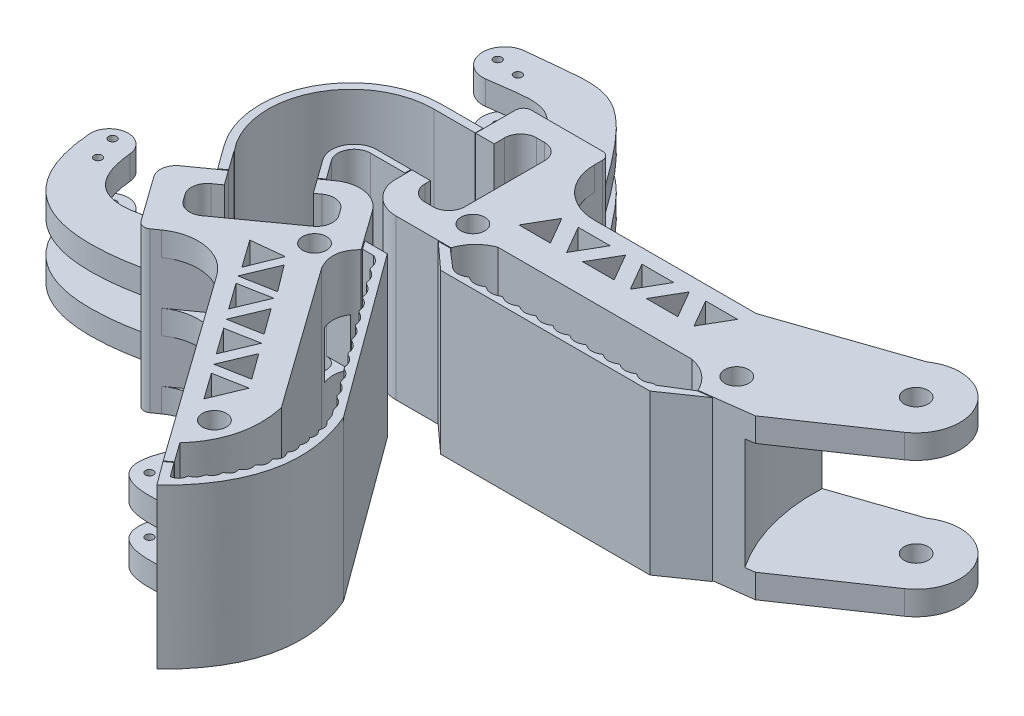
from build123d import *

# Parameters (mm, degrees)
EXTRUDE_1_DEPTH      = 20
EXTRUDE_3_DEPTH      = 20
CUT_EXTRUDE_5_DEPTH  = 5.5
CUT_EXTRUDE_6_DEPTH  = 5.5
CUT_EXTRUDE_8_DEPTH  = 35.5
EXTRUDE_5_DEPTH      = 20
SKETCH_13_R          = 22.138459571
CUT_EXTRUDE_10_DEPTH = 7
SKETCH_14_R          = 1.5
CUT_EXTRUDE_11_DEPTH = 24
SKETCH_15_R          = 1.5
CUT_EXTRUDE_12_DEPTH = 24
CUT_EXTRUDE_14_DEPTH = 3
SKETCH_17_W          = 3.321417058
SKETCH_17_H          = 8
CUT_EXTRUDE_15_DEPTH = 26
EXTRUDE_6_DEPTH      = 20
EXTRUDE_6_2_DEPTH    = 20
EXTRUDE_7_DEPTH      = 20
CUT_EXTRUDE_17_DEPTH = 30
CUT_EXTRUDE_20_DEPTH = 5.5
CUT_EXTRUDE_21_DEPTH = 5.5
CUT_EXTRUDE_23_DEPTH = 35.5
CUT_EXTRUDE_24_DEPTH = 35.5
CUT_EXTRUDE_25_DEPTH = 35.5
SKETCH_33_R          = 1.5
CUT_EXTRUDE_26_DEPTH = 20
EXTRUDE_9_DEPTH      = 20
CUT_EXTRUDE_27_DEPTH = 3
EXTRUDE_10_DEPTH     = 5
CUT_EXTRUDE_28_DEPTH = 2
SKETCH_37_R          = 0.5
CUT_EXTRUDE_29_DEPTH = 7
EXTRUDE_13_DEPTH     = 5
EXTRUDE_14_DEPTH     = 5
SKETCH_45_W          = 26.316708413
SKETCH_45_H          = 13.598677245
CUT_EXTRUDE_31_DEPTH = 2
SKETCH_46_R          = 0.5
CUT_EXTRUDE_32_DEPTH = 12


with BuildPart() as part:
    # 草图1 → 凸台-拉伸1 (new body)
    with BuildSketch(Plane(origin=(0, 0, 0), x_dir=(1, 0, 0), z_dir=(0, 1, 0))):
        with BuildLine():
            Line((-17.757352941, 11.257352941), (-17.757352941, 12.257352941))
            ThreePointArc((-17.757352941, 12.257352941), (-18.05024616, 12.964459722), (-18.757352941, 13.257352941))
            Line((-18.757352941, 13.257352941), (-27.669117647, 13.257352941))
            ThreePointArc((-27.669117647, 13.257352941), (-28.376224428, 12.964459722), (-28.669117647, 12.257352941))
            Line((-28.669117647, 12.257352941), (-28.669117647, -2.742647059))
            ThreePointArc((-28.669117647, -2.742647059), (-27.497544772, -5.571074184), (-24.669117647, -6.742647059))
            Line((-24.669117647, -6.742647059), (-17.757352941, -6.742647059))
            add(Edge.make_bspline(
                [(-17.757352941, -6.742647059), (-16.974723436, -4.564731842), (-14.875, -3.742647059)],
                knots=[0, 0, 0, 1, 1, 1], degree=2))
            Line((-14.875, -3.742647059), (9.513778538, -3.742647059))
            add(Edge.make_bspline(
                [(9.513778538, -3.742647059), (12.09253878, -4.324174608), (13.242647059, -6.742647059)],
                knots=[0, 0, 0, 1, 1, 1], degree=2))
            Line((13.242647059, -6.742647059), (13.242647059, -3.742647059))
            Line((13.242647059, -3.742647059), (13.242647059, 5.257352941))
            Line((13.242647059, 5.257352941), (-11.757352941, 5.257352941))
            ThreePointArc((-11.757352941, 5.257352941), (-15.999993628, 7.014712254), (-17.757352941, 11.257352941))
        make_face()
    extrude(amount=EXTRUDE_1_DEPTH)

    # 草图2 → 凸台-拉伸3 (add)
    with BuildSketch(Plane(origin=(0, 20, 0), x_dir=(1, 0, 0), z_dir=(0, 1, 0))):
        with BuildLine():
            Line((13.242647059, 5.257352941), (8.547982685, 5.257352941))
            Line((8.547982685, 5.257352941), (8.547982685, 2.006423608))
            add(Edge.make_bspline(
                [(8.547982685, 2.006423608), (12.006655634, -1.762879717), (13.242647059, -6.742647059)],
                knots=[0, 0, 0, 1, 1, 1], degree=2))
            Line((13.242647059, -6.742647059), (13.242647059, 5.257352941))
        make_face()
        with BuildLine():
            ThreePointArc((30.777158792, 1.656960808), (32.220492243, 9.321684017), (24.547982685, 10.723037078))
            Line((24.547982685, 10.723037078), (8.547982685, 5.257352941))
            Line((8.547982685, 5.257352941), (13.242647059, 5.257352941))
            Line((13.242647059, 5.257352941), (13.242647059, -6.742647059))
            Line((13.242647059, -6.742647059), (19.621377553, -5.918458307))
            Line((19.621377553, -5.918458307), (30.777158792, 1.656960808))
        make_face()
    extrude(amount=-EXTRUDE_3_DEPTH)

    # 草图3 → 切除-拉伸5 (cut)
    with BuildSketch(Plane(origin=(0, 17, 0), x_dir=(1, 0, 0), z_dir=(0, 1, 0))):
        Polygon((8.55906196, -0.742647059), (16.547982685, 12.911519067), (8.547982685, 12.911519067), (-17.757352941, 12.911519067), (-17.757352941, -0.742647059), align=None)
    extrude(amount=-CUT_EXTRUDE_5_DEPTH, mode=Mode.SUBTRACT)

    # 草图8 → 切除-拉伸6 (cut)
    with BuildSketch(Plane(origin=(0, 3, 0), x_dir=(-1, 0, 0), z_dir=(0, -1, 0))):
        Polygon((17.757352941, 13.042470794), (-8.547982685, 13.042470794), (-16.547982685, 13.042470794), (-8.547982685, -0.742647059), (17.757352941, -0.742647059), align=None)
    extrude(amount=-CUT_EXTRUDE_6_DEPTH, mode=Mode.SUBTRACT)

    # 草图9 → 切除-拉伸8 (cut)
    with BuildSketch(Plane(origin=(0, 20, 0), x_dir=(1, 0, 0), z_dir=(0, 1, 0))):
        Polygon((-11.984193544, 3.457352941), (-7.984193544, 3.457352941), (-9.984193544, -0.006748674), align=None)
        Polygon((-1.984193544, -0.006748674), (-3.984193544, 3.457352941), (0.015806456, 3.457352941), align=None)
        Polygon((6.015806456, -0.006748674), (4.015806456, 3.457352941), (8.015806456, 3.457352941), align=None)
        Polygon((-5.991757146, 3.412680143), (-7.965965294, -0.006748674), (-4.017548998, -0.006748674), align=None)
        Polygon((2.008242854, 3.412680143), (3.982451002, -0.006748674), (0.034034706, -0.006748674), align=None)
        Polygon((-13.991757146, 3.412680143), (-12.017548998, -0.006748674), (-15.965965294, -0.006748674), align=None)
    extrude(amount=-CUT_EXTRUDE_8_DEPTH, mode=Mode.SUBTRACT)

    # 草图13 → 切除-拉伸10 (cut, symmetric)
    with BuildSketch(Plane(origin=(0, 10, 0), x_dir=(1, 0, 0), z_dir=(0, 1, 0))):
        with Locations((36.841923503, 6.266009929)):
            Circle(SKETCH_13_R)
    extrude(amount=CUT_EXTRUDE_10_DEPTH, both=True, mode=Mode.SUBTRACT)

    # 草图14 → 切除-拉伸11 (cut)
    with BuildSketch(Plane(origin=(0, 20, 0), x_dir=(1, 0, 0), z_dir=(0, 1, 0))):
        with Locations((27.687386184, 6.207049294)):
            Circle(SKETCH_14_R)
    extrude(amount=-CUT_EXTRUDE_11_DEPTH, mode=Mode.SUBTRACT)

    # 草图15 → 切除-拉伸12 (cut)
    with BuildSketch(Plane(origin=(0, 20, 0), x_dir=(1, 0, 0), z_dir=(0, 1, 0))):
        with Locations((14.173405038, -2.798015611)):
            Circle(SKETCH_15_R)
        with Locations((-18.955674647, -2.798015611)):
            Circle(SKETCH_15_R)
        with BuildLine():
            Line((-24.337793982, 10.577806362), (-23.337793982, 10.577806362))
            ThreePointArc((-23.337793982, 10.577806362), (-21.92358042, 9.992019924), (-21.337793982, 8.577806362))
            Line((-21.337793982, 8.577806362), (-21.337793982, -1.422193638))
            ThreePointArc((-21.337793982, -1.422193638), (-21.92358042, -2.8364072), (-23.337793982, -3.422193638))
            Line((-23.337793982, -3.422193638), (-24.337793982, -3.422193638))
            ThreePointArc((-24.337793982, -3.422193638), (-25.752007544, -2.8364072), (-26.337793982, -1.422193638))
            Line((-26.337793982, -1.422193638), (-26.337793982, 8.577806362))
            ThreePointArc((-26.337793982, 8.577806362), (-25.752007544, 9.992019924), (-24.337793982, 10.577806362))
        make_face()
    extrude(amount=-CUT_EXTRUDE_12_DEPTH, mode=Mode.SUBTRACT)

    # 草图16 → 切除-拉伸14 (cut, symmetric)
    with BuildSketch(Plane(origin=(0, 10, 0), x_dir=(1, 0, 0), z_dir=(0, 1, 0))):
        Polygon((13.082513901, -1.76847371), (10.798371522, -4.188725545), (12.980771161, -6.247155195), (15.264296175, -3.827557513), align=None)
        Polygon((-19.51774749, -4.188725545), (-17.420439331, -5.97897681), (-15.447703428, -4.005018797), (-17.935814388, -1.698067862), align=None)
    extrude(amount=CUT_EXTRUDE_14_DEPTH, both=True, mode=Mode.SUBTRACT)

    # 草图17 → 切除-拉伸15 (cut)
    with BuildSketch(Plane(origin=(0, 20, 0), x_dir=(1, 0, 0), z_dir=(0, 1, 0))):
        with Locations((-27.998502511, 3.257352941)):
            Rectangle(SKETCH_17_W, SKETCH_17_H)
    extrude(amount=-CUT_EXTRUDE_15_DEPTH, mode=Mode.SUBTRACT)

    # 草图42 → 凸台-拉伸13 (add, symmetric)
    with BuildSketch(Plane(origin=(0, 10, 0), x_dir=(1, 0, 0), z_dir=(0, 1, 0))):
        with BuildLine():
            Line((-18.757352941, 13.257352941), (-27.669117647, 13.257352941))
            add(Edge.make_bspline(
                [(-27.669117647, 13.257352941), (-30.783867563, 20.913364448), (-33.058316608, 19.487699172), (-38.943109416, 18.775725984)],
                knots=[0, 0, 0, 0, 0.972018538, 0.972018538, 0.972018538, 0.972018538], degree=3))
            ThreePointArc((-38.943109416, 18.775725984), (-42.024959974, 21.238488901), (-39.505880976, 24.274480509))
            add(Edge.make_bspline(
                [(-18.757352941, 13.257352941), (-28.734678955, 27.257974916), (-29.354714717, 25.124898659), (-39.505880976, 24.274480509)],
                knots=[0, 0, 0, 0, 0.985963459, 0.985963459, 0.985963459, 0.985963459], degree=3))
        make_face()
    extrude(amount=EXTRUDE_13_DEPTH, both=True)


with BuildPart() as body_2:
    # 草图11 → 凸台-拉伸5 (new body)
    with BuildSketch(Plane(origin=(0, 20, 0), x_dir=(1, 0, 0), z_dir=(0, 1, 0))):
        with BuildLine():
            Line((-17.757352941, -6.842647059), (-19.257352941, -6.842647059))
            Line((-19.257352941, -6.842647059), (-15.958332753, -9.842647059))
            Line((-15.958332753, -9.842647059), (10.311604906, -9.842647059))
            Line((10.311604906, -9.842647059), (14.961412516, -6.621398556))
            Line((14.961412516, -6.621398556), (13.275427967, -6.839242766))
            Line((13.275427967, -6.839242766), (12.036564655, -7.603938962))
            Line((12.036564655, -7.603938962), (10.311604906, -8.668681251))
            Line((10.311604906, -8.668681251), (10.055078303, -8.827023916))
            Line((10.055078303, -8.827023916), (9.648844043, -8.827023916))
            add(Edge.make_bspline(
                [(7.648844043, -8.827023916), (8.572627963, -9.50139068), (9.648844043, -8.827023916)],
                knots=[0, 0, 0, 1, 1, 1], degree=2))
            Line((7.648844043, -8.827023916), (7.548844043, -8.827023916))
            add(Edge.make_bspline(
                [(5.548844043, -8.827023916), (6.472627963, -9.50139068), (7.548844043, -8.827023916)],
                knots=[0, 0, 0, 1, 1, 1], degree=2))
            Line((5.548844043, -8.827023916), (5.448844043, -8.827023916))
            add(Edge.make_bspline(
                [(3.448844043, -8.827023916), (4.372627963, -9.50139068), (5.448844043, -8.827023916)],
                knots=[0, 0, 0, 1, 1, 1], degree=2))
            Line((3.448844043, -8.827023916), (3.348844043, -8.827023916))
            add(Edge.make_bspline(
                [(1.348844043, -8.827023916), (2.272627963, -9.50139068), (3.348844043, -8.827023916)],
                knots=[0, 0, 0, 1, 1, 1], degree=2))
            Line((1.348844043, -8.827023916), (1.248844043, -8.827023916))
            add(Edge.make_bspline(
                [(-0.751155957, -8.827023916), (0.172627963, -9.50139068), (1.248844043, -8.827023916)],
                knots=[0, 0, 0, 1, 1, 1], degree=2))
            Line((-0.751155957, -8.827023916), (-0.851155957, -8.827023916))
            add(Edge.make_bspline(
                [(-2.851155957, -8.827023916), (-1.927372037, -9.50139068), (-0.851155957, -8.827023916)],
                knots=[0, 0, 0, 1, 1, 1], degree=2))
            Line((-2.851155957, -8.827023916), (-2.951155957, -8.827023916))
            add(Edge.make_bspline(
                [(-4.951155957, -8.827023916), (-4.027372037, -9.50139068), (-2.951155957, -8.827023916)],
                knots=[0, 0, 0, 1, 1, 1], degree=2))
            Line((-4.951155957, -8.827023916), (-5.051155957, -8.827023916))
            add(Edge.make_bspline(
                [(-7.051155957, -8.827023916), (-6.127372037, -9.50139068), (-5.051155957, -8.827023916)],
                knots=[0, 0, 0, 1, 1, 1], degree=2))
            Line((-7.051155957, -8.827023916), (-7.151155957, -8.827023916))
            add(Edge.make_bspline(
                [(-9.151155957, -8.827023916), (-8.227372037, -9.50139068), (-7.151155957, -8.827023916)],
                knots=[0, 0, 0, 1, 1, 1], degree=2))
            Line((-9.151155957, -8.827023916), (-9.251155957, -8.827023916))
            add(Edge.make_bspline(
                [(-11.251155957, -8.827023916), (-10.327372037, -9.50139068), (-9.251155957, -8.827023916)],
                knots=[0, 0, 0, 1, 1, 1], degree=2))
            Line((-11.251155957, -8.827023916), (-11.351155957, -8.827023916))
            add(Edge.make_bspline(
                [(-13.351155957, -8.827023916), (-12.427372037, -9.50139068), (-11.351155957, -8.827023916)],
                knots=[0, 0, 0, 1, 1, 1], degree=2))
            Line((-13.351155957, -8.827023916), (-13.451155957, -8.827023916))
            add(Edge.make_bspline(
                [(-15.451155957, -8.827023916), (-14.527372037, -9.50139068), (-13.451155957, -8.827023916)],
                knots=[0, 0, 0, 1, 1, 1], degree=2))
            Line((-15.451155957, -8.827023916), (-16.547976455, -7.883260123))
            Line((-16.547976455, -7.883260123), (-16.620330488, -7.821002792))
            Line((-16.620330488, -7.821002792), (-17.757352941, -6.842647059))
        make_face()
    extrude(amount=-EXTRUDE_5_DEPTH)


with BuildPart() as body_3:
    # 草图18 → 凸台-拉伸6 (new body)
    with BuildSketch(Plane(origin=(0, 20, 0), x_dir=(1, 0, 0), z_dir=(0, 1, 0))):
        with BuildLine():
            Line((-33.911966998, 8.257352941), (-28.719117647, 8.257352941))
            Line((-28.719117647, 8.257352941), (-28.719117647, 7.257352941))
            Line((-28.719117647, 7.257352941), (-31.669117647, 7.257352941))
            Line((-31.669117647, 7.257352941), (-33.911966998, 7.257352941))
            ThreePointArc((-33.911966998, 7.257352941), (-43.343138508, 1.235428199), (-41.848458952, -9.854049096))
            Line((-41.848458952, -9.854049096), (-41.875191428, -9.87324066))
            Line((-41.875191428, -9.87324066), (-40.125630208, -12.310254311))
            Line((-40.125630208, -12.310254311), (-40.925598211, -12.881747428))
            Line((-40.925598211, -12.881747428), (-43.139951125, -9.826043873))
            ThreePointArc((-43.139951125, -9.826043873), (-44.062889756, 2.041158453), (-33.911966998, 8.257352941))
        make_face()
    extrude(amount=-EXTRUDE_6_DEPTH)

    # 草图21 → 凸台-拉伸7 (add)
    with BuildSketch(Plane(origin=(0, 20, 0), x_dir=(1, 0, 0), z_dir=(0, 1, 0))):
        with BuildLine():
            Line((-43.684350566, -14.852586231), (-32.292670658, -6.714427417))
            ThreePointArc((-32.292670658, -6.714427417), (-29.310171903, -6.023569849), (-26.712716737, -7.644004873))
            Line((-26.712716737, -7.644004873), (-23.179903306, -12.589187279))
            add(Edge.make_bspline(
                [(-23.179903306, -12.589187279), (-25.117782684, -14.52549484), (-23.68385175, -17.044639854)],
                knots=[0, 0, 0, 1, 1, 1], degree=2))
            Line((-23.68385175, -17.044639854), (-9.717560383, -36.594457496))
            add(Edge.make_bspline(
                [(-12.643834419, -47.980917872), (-5.534754551, -43.034001576), (-9.717560383, -36.594457496)],
                knots=[0, 0, 0, 1, 1, 1], degree=2))
            Line((-12.643834419, -47.980917872), (-29.501449104, -24.383866634))
            ThreePointArc((-29.501449104, -24.383866634), (-33.397631852, -21.953214099), (-37.871379985, -22.989500451))
            Line((-37.871379985, -22.989500451), (-38.685071407, -23.570797509))
            ThreePointArc((-38.685071407, -23.570797509), (-39.430696095, -23.743511901), (-40.080059887, -23.338403145))
            Line((-40.080059887, -23.338403145), (-44.149139294, -17.642563191))
            ThreePointArc((-44.149139294, -17.642563191), (-44.494568077, -16.151313814), (-43.684350566, -14.852586231))
        make_face()
    extrude(amount=-EXTRUDE_7_DEPTH)


with BuildPart() as body_4:
    # 草图18 → Extrude 6 2 (new body)
    with BuildSketch(Plane(origin=(0, 20, 0), x_dir=(1, 0, 0), z_dir=(0, 1, 0))):
        with BuildLine():
            ThreePointArc((-33.085434119, -0.742647059), (-35.594717924, -2.275448051), (-35.376488359, -5.207744072))
            Line((-35.376488359, -5.207744072), (-33.626927138, -7.644757723))
            Line((-33.626927138, -7.644757723), (-32.977742282, -7.185057851))
            Line((-32.977742282, -7.185057851), (-34.742106275, -4.776594347))
            ThreePointArc((-34.742106275, -4.776594347), (-34.917073129, -2.634234233), (-33.085434119, -1.509325882))
            Line((-33.085434119, -1.509325882), (-28.769117647, -1.509325882))
            Line((-28.769117647, -1.509325882), (-28.769117647, -0.742647059))
            Line((-28.769117647, -0.742647059), (-31.669117647, -0.742647059))
            Line((-31.669117647, -0.742647059), (-33.085434119, -0.742647059))
        make_face()
    extrude(amount=-EXTRUDE_6_2_DEPTH)


with BuildPart() as cut_extrude_17_tool:
    # 草图22 → 切除-拉伸17 (new body)
    with BuildSketch(Plane(origin=(0, 20, 0), x_dir=(1, 0, 0), z_dir=(0, 1, 0))):
        Polygon((-32.977742282, -7.185057851), (-40.925598211, -12.881747428), (-40.984277833, -12.800772292), (-33.036841683, -7.104383595), align=None)
    extrude(amount=-CUT_EXTRUDE_17_DEPTH)


with BuildPart() as body_3_1:
    add(body_3.part)

    # 切除-拉伸17: cut by cut_extrude_17_tool
    add(cut_extrude_17_tool.part, mode=Mode.SUBTRACT)

    # 草图25 → 切除-拉伸20 (cut)
    with BuildSketch(Plane(origin=(0, 3, 0), x_dir=(-1, 0, 0), z_dir=(0, -1, 0))):
        Polygon((28.107082921, -16.013935753), (38.685071407, -23.570797509), (23.571347896, -44.726774481), (12.99335941, -37.169912725), align=None)
    extrude(amount=-CUT_EXTRUDE_20_DEPTH, mode=Mode.SUBTRACT)

    # 草图26 → 切除-拉伸21 (cut)
    with BuildSketch(Plane(origin=(0, 17, 0), x_dir=(1, 0, 0), z_dir=(0, 1, 0))):
        Polygon((-38.278225696, -23.28014898), (-28.107082921, -16.013935753), (-12.99335941, -37.169912725), (-23.164502185, -44.436125952), align=None)
    extrude(amount=-CUT_EXTRUDE_21_DEPTH, mode=Mode.SUBTRACT)

    # 草图28 → 切除-拉伸23 (cut)
    with BuildSketch(Plane(origin=(0, 20, 0), x_dir=(1, 0, 0), z_dir=(0, 1, 0))):
        with BuildLine():
            Line((-39.792561941, -14.844882964), (-38.811583772, -14.140627015))
            Line((-38.811583772, -14.140627015), (-40.126526253, -12.309006184))
            Line((-40.126526253, -12.309006184), (-33.616081242, -7.659865281))
            Line((-33.616081242, -7.659865281), (-32.312880703, -9.475130427))
            Line((-32.312880703, -9.475130427), (-31.669183104, -9.013012229))
            ThreePointArc((-31.669183104, -9.013012229), (-30.178740773, -8.664117675), (-28.878133189, -9.471313849))
            Line((-28.878133189, -9.471313849), (-28.294946116, -10.283651733))
            ThreePointArc((-28.294946116, -10.283651733), (-27.946051562, -11.774094064), (-28.753247736, -13.074701648))
            Line((-28.753247736, -13.074701648), (-36.876626573, -18.906572383))
            ThreePointArc((-36.876626573, -18.906572383), (-38.367068904, -19.255466937), (-39.667676487, -18.448270762))
            Line((-39.667676487, -18.448270762), (-40.250863561, -17.635932879))
            ThreePointArc((-40.250863561, -17.635932879), (-40.599758115, -16.145490548), (-39.792561941, -14.844882964))
        make_face()
    extrude(amount=-CUT_EXTRUDE_23_DEPTH, mode=Mode.SUBTRACT)

    # 草图29 → 切除-拉伸24 (cut)
    with BuildSketch(Plane(origin=(0, 20, 0), x_dir=(1, 0, 0), z_dir=(0, 1, 0))):
        Polygon((-16.829422156, -38.681409536), (-19.154610388, -35.426643848), (-15.154610388, -34.681409536), align=None)
        Polygon((-19.269107154, -29.018290575), (-20.943918922, -33.018290575), (-23.269107154, -29.763524887), align=None)
        Polygon((-23.38360392, -23.355171614), (-25.058415688, -27.355171614), (-27.38360392, -24.100405926), align=None)
        Polygon((-19.965883911, -34.291034615), (-15.965883911, -33.545800303), (-18.30515841, -30.324677242), align=None)
        Polygon((-22.419655176, -24.661558281), (-20.080380677, -27.882681342), (-24.080380677, -28.627915654), align=None)
        Polygon((-28.065082121, -23.191248182), (-23.858053166, -22.407442599), (-26.350480402, -19.096216722), align=None)
        Polygon((-27.196998621, -18.109391937), (-28.75684514, -21.985571094), (-31.215232137, -18.544355654), align=None)
    extrude(amount=-CUT_EXTRUDE_24_DEPTH, mode=Mode.SUBTRACT)

    # 草图30 → 切除-拉伸25 (cut)
    with BuildSketch(Plane(origin=(0, 20, 0), x_dir=(1, 0, 0), z_dir=(0, 1, 0))):
        with BuildLine():
            Line((-11.838705387, -47.387635301), (-13.566970683, -44.968433918))
            add(Edge.make_bspline(
                [(-13.566970683, -44.968433918), (-9.73332043, -40.692832272), (-11.004702715, -34.792733816)],
                knots=[0, 0, 0, 1, 1, 1], degree=2))
            Line((-11.004702715, -34.792733816), (-4.435956424, -42.099148685))
            Line((-4.435956424, -42.099148685), (-11.838705387, -47.387635301))
        make_face()
    extrude(amount=-CUT_EXTRUDE_25_DEPTH, mode=Mode.SUBTRACT)

    # 草图33 → 切除-拉伸26 (cut)
    with BuildSketch(Plane(origin=(0, 20, 0), x_dir=(1, 0, 0), z_dir=(0, 1, 0))):
        with Locations((-26.789347485, -14.840526908)):
            Circle(SKETCH_33_R)
        with Locations((-13.850284783, -40.347116646)):
            Circle(SKETCH_33_R)
    extrude(amount=-CUT_EXTRUDE_26_DEPTH, mode=Mode.SUBTRACT)

    # 草图34 → 切除-拉伸27 (cut, symmetric)
    with BuildSketch(Plane(origin=(0, 10, 0), x_dir=(1, 0, 0), z_dir=(0, 1, 0))):
        Polygon((-26.789347485, -13.340526908), (-23.791084433, -13.340526908), (-24.023266754, -16.340526908), (-26.789347485, -16.340526908), align=None)
        Polygon((-15.001116993, -41.309190044), (-12.766425918, -43.982327535), (-10.66835741, -42.228382971), (-11.324577914, -41.309190044), (-12.766425918, -39.310174043), align=None)
    extrude(amount=CUT_EXTRUDE_27_DEPTH, both=True, mode=Mode.SUBTRACT)

    # 草图35 → 凸台-拉伸10 (add, symmetric)
    with BuildSketch(Plane(origin=(0, 10, 0), x_dir=(1, 0, 0), z_dir=(0, 1, 0))):
        with BuildLine():
            Line((-17.875507942, -40.657695074), (-12.959830436, -47.538591104))
            add(Edge.make_bspline(
                [(-17.875507942, -40.657695074), (-21.798639443, -48.453537753), (-12.959830436, -47.538591104)],
                knots=[0, 0, 0, 1, 1, 1], degree=2))
        make_face()
    extrude(amount=EXTRUDE_10_DEPTH, both=True)

    # 草图36 → 切除-拉伸28 (cut, symmetric)
    with BuildSketch(Plane(origin=(0, 10, 0), x_dir=(1, 0, 0), z_dir=(0, 1, 0))):
        Polygon((-17.875507942, -40.657695074), (-12.959830436, -47.538591104), (-18.464251545, -51.470921851), (-23.7313276, -44.098143089), align=None)
    extrude(amount=CUT_EXTRUDE_28_DEPTH, both=True, mode=Mode.SUBTRACT)

    # 草图37 → 切除-拉伸29 (cut, symmetric)
    with BuildSketch(Plane(origin=(0, 10, 0), x_dir=(1, 0, 0), z_dir=(0, 1, 0))):
        with Locations((-17.218769945, -45.134583728)):
            Circle(SKETCH_37_R)
    extrude(amount=CUT_EXTRUDE_29_DEPTH, both=True, mode=Mode.SUBTRACT)

    # 草图43 → 凸台-拉伸14 (add, symmetric)
    with BuildSketch(Plane(origin=(0, 10, 0), x_dir=(1, 0, 0), z_dir=(0, 1, 0))):
        with BuildLine():
            Line((-44.413920636, -17.127822986), (-40.080059887, -23.338403145))
            add(Edge.make_bspline(
                [(-40.080059887, -23.338403145), (-56.61287815, -26.678968714), (-57.802433661, -12.286596073)],
                knots=[0, 0, 0, 1, 1, 1], degree=2))
            ThreePointArc((-57.802433661, -12.286596073), (-55.757644362, -9.567935606), (-53.108185808, -11.701628974))
            add(Edge.make_bspline(
                [(-44.413920636, -17.127822986), (-52.359768991, -19.916477262), (-53.108185808, -11.701628974)],
                knots=[0, 0, 0, 1, 1, 1], degree=2))
        make_face()
    extrude(amount=EXTRUDE_14_DEPTH, both=True)


with BuildPart() as body_4_1:
    add(body_4.part)

    # 切除-拉伸17: cut by cut_extrude_17_tool
    add(cut_extrude_17_tool.part, mode=Mode.SUBTRACT)


with BuildPart() as body_5:
    # 草图31 → 凸台-拉伸9 (new body)
    with BuildSketch(Plane(origin=(0, 20, 0), x_dir=(1, 0, 0), z_dir=(0, 1, 0))):
        with BuildLine():
            Line((-23.906716895, -11.399774786), (-23.152653731, -12.455301767))
            Line((-23.152653731, -12.455301767), (-21.74134621, -12.455301767))
            add(Edge.make_bspline(
                [(-21.74134621, -12.455301767), (-20.715348251, -12.903361863), (-20.607642042, -13.991405193)],
                knots=[0, 0, 0, 1, 1, 1], degree=2))
            Line((-20.607642042, -13.991405193), (-20.43493565, -14.225412342))
            add(Edge.make_bspline(
                [(-20.43493565, -14.225412342), (-19.408937691, -14.673472438), (-19.301231482, -15.761515768)],
                knots=[0, 0, 0, 1, 1, 1], degree=2))
            Line((-19.301231482, -15.761515768), (-19.12852509, -15.995522918))
            add(Edge.make_bspline(
                [(-19.12852509, -15.995522918), (-18.102527131, -16.443583013), (-17.994820922, -17.531626344)],
                knots=[0, 0, 0, 1, 1, 1], degree=2))
            Line((-17.994820922, -17.531626344), (-17.82211453, -17.765633493))
            add(Edge.make_bspline(
                [(-17.82211453, -17.765633493), (-16.796116571, -18.213693589), (-16.688410362, -19.301736919)],
                knots=[0, 0, 0, 1, 1, 1], degree=2))
            Line((-16.688410362, -19.301736919), (-16.51570397, -19.535744069))
            add(Edge.make_bspline(
                [(-16.51570397, -19.535744069), (-15.489706012, -19.983804164), (-15.381999803, -21.071847494)],
                knots=[0, 0, 0, 1, 1, 1], degree=2))
            Line((-15.381999803, -21.071847494), (-15.20929341, -21.305854644))
            add(Edge.make_bspline(
                [(-15.20929341, -21.305854644), (-14.183295452, -21.753914739), (-14.075589243, -22.84195807)],
                knots=[0, 0, 0, 1, 1, 1], degree=2))
            Line((-14.075589243, -22.84195807), (-13.90288285, -23.075965219))
            add(Edge.make_bspline(
                [(-13.90288285, -23.075965219), (-12.876884892, -23.524025315), (-12.769178683, -24.612068645)],
                knots=[0, 0, 0, 1, 1, 1], degree=2))
            Line((-12.769178683, -24.612068645), (-12.596472291, -24.846075795))
            add(Edge.make_bspline(
                [(-12.596472291, -24.846075795), (-11.570474332, -25.29413589), (-11.462768123, -26.38217922)],
                knots=[0, 0, 0, 1, 1, 1], degree=2))
            Line((-11.462768123, -26.38217922), (-11.290061731, -26.61618637))
            add(Edge.make_bspline(
                [(-11.290061731, -26.61618637), (-10.264063772, -27.064246466), (-10.156357563, -28.152289796)],
                knots=[0, 0, 0, 1, 1, 1], degree=2))
            Line((-10.156357563, -28.152289796), (-9.983651171, -28.386296945))
            add(Edge.make_bspline(
                [(-9.983651171, -28.386296945), (-8.957653212, -28.834357041), (-8.849947003, -29.922400371)],
                knots=[0, 0, 0, 1, 1, 1], degree=2))
            Line((-8.849947003, -29.922400371), (-8.677240611, -30.156407521))
            add(Edge.make_bspline(
                [(-8.677240611, -30.156407521), (-7.651242652, -30.604467616), (-7.543536443, -31.692510947)],
                knots=[0, 0, 0, 1, 1, 1], degree=2))
            Line((-7.543536443, -31.692510947), (-6.969903483, -32.469750354))
            add(Edge.make_bspline(
                [(-6.645360583, -33.409236544), (-6.79455977, -32.942243027), (-6.969903483, -32.469750354)],
                knots=[0.950269999, 0.950269999, 0.950269999, 1, 1, 1], degree=2))
            add(Edge.make_bspline(
                [(-6.232510716, -34.899547114), (-5.927497929, -33.999916773), (-6.645360583, -33.409236544)],
                knots=[0, 0, 0, 1, 1, 1], degree=2))
            add(Edge.make_bspline(
                [(-5.96862688, -36.271289191), (-5.564841599, -35.514572864), (-6.232510716, -34.899547114)],
                knots=[0, 0, 0, 1, 1, 1], degree=2))
            add(Edge.make_bspline(
                [(-5.818873322, -37.703822273), (-5.421182345, -36.920842137), (-5.96862688, -36.271289191)],
                knots=[0, 0, 0, 1, 1, 1], degree=2))
            add(Edge.make_bspline(
                [(-5.809835223, -39.236443867), (-5.196203032, -38.494732813), (-5.818873322, -37.703822273)],
                knots=[0, 0, 0, 1, 1, 1], degree=2))
            add(Edge.make_bspline(
                [(-5.997763033, -40.949929267), (-5.108294849, -40.190057247), (-5.809835223, -39.236443867)],
                knots=[0, 0, 0, 1, 1, 1], degree=2))
            add(Edge.make_bspline(
                [(-6.408947411, -42.656340795), (-5.487653527, -41.994082025), (-5.997763033, -40.949929267)],
                knots=[0, 0, 0, 1, 1, 1], degree=2))
            add(Edge.make_bspline(
                [(-6.969903498, -44.155825868), (-6.12182617, -43.62057452), (-6.408947411, -42.656340795)],
                knots=[0, 0, 0, 1, 1, 1], degree=2))
            add(Edge.make_bspline(
                [(-7.628527545, -45.472357712), (-6.678564217, -45.10281094), (-6.969903498, -44.155825868)],
                knots=[0, 0, 0, 1, 1, 1], degree=2))
            add(Edge.make_bspline(
                [(-8.491671843, -46.842628103), (-7.584828256, -46.461046501), (-7.628527545, -45.472357712)],
                knots=[0, 0, 0, 1, 1, 1], degree=2))
            add(Edge.make_bspline(
                [(-9.423109387, -48.061422042), (-8.548665511, -47.729098078), (-8.491671843, -46.842628103)],
                knots=[0, 0, 0, 1, 1, 1], degree=2))
            add(Edge.make_bspline(
                [(-10.489751222, -49.248457216), (-9.494268081, -49.031590857), (-9.423109387, -48.061422042)],
                knots=[0, 0, 0, 1, 1, 1], degree=2))
            Line((-10.489751222, -49.248457216), (-11.793801144, -47.47876348))
            Line((-11.793801144, -47.47876348), (-12.584512597, -48.061422042))
            Line((-12.584512597, -48.061422042), (-10.394022913, -51.034081149))
            add(Edge.make_bspline(
                [(-10.394022913, -51.034081149), (-1.534275496, -42.401972786), (-6.089891083, -31.898129224)],
                knots=[0, 0, 0, 1, 1, 1], degree=2))
            Line((-6.089891083, -31.898129224), (-21.096332803, -11.399774786))
            Line((-21.096332803, -11.399774786), (-23.906716895, -11.399774786))
        make_face()
    extrude(amount=-EXTRUDE_9_DEPTH)


with BuildPart() as cut_extrude_31_tool:
    # 草图45 → 切除-拉伸31 (new body, symmetric)
    with BuildSketch(Plane(origin=(0, 10, 0), x_dir=(1, 0, 0), z_dir=(0, 1, 0))):
        with Locations((-31.208600367, 20.056691564)):
            Rectangle(SKETCH_45_W, SKETCH_45_H)
        Polygon((-40.080059887, -23.338403145), (-44.149139294, -17.642563191), (-50.966363326, -8.099909156), (-59.828000764, -9.297467315), (-54.417568339, -27.878438098), align=None)
    extrude(amount=CUT_EXTRUDE_31_DEPTH, both=True)


with BuildPart() as part_1:
    add(part.part)

    # 切除-拉伸31: cut by cut_extrude_31_tool
    add(cut_extrude_31_tool.part, mode=Mode.SUBTRACT)


with BuildPart() as body_3_2:
    add(body_3_1.part)

    # 切除-拉伸31: cut by cut_extrude_31_tool
    add(cut_extrude_31_tool.part, mode=Mode.SUBTRACT)


with BuildPart() as cut_extrude_32_tool:
    # 草图46 → 切除-拉伸32 (new body, symmetric)
    with BuildSketch(Plane(origin=(0, 10, 0), x_dir=(1, 0, 0), z_dir=(0, 1, 0))):
        with Locations((-40.284616885, 21.646227961)):
            Circle(SKETCH_46_R)
        with Locations((-37.353858113, 21.249257528)):
            Circle(SKETCH_46_R)
        with Locations((-55.84604882, -11.12884755)):
            Circle(SKETCH_46_R)
        with Locations((-54.715645648, -14.095840638)):
            Circle(SKETCH_46_R)
    extrude(amount=CUT_EXTRUDE_32_DEPTH, both=True)


with BuildPart() as part_2:
    add(part_1.part)

    # 切除-拉伸32: cut by cut_extrude_32_tool
    add(cut_extrude_32_tool.part, mode=Mode.SUBTRACT)


with BuildPart() as body_3_3:
    add(body_3_2.part)

    # 切除-拉伸32: cut by cut_extrude_32_tool
    add(cut_extrude_32_tool.part, mode=Mode.SUBTRACT)


solid = Compound([body_2.part, body_4_1.part, body_5.part, part_2.part, body_3_3.part])
